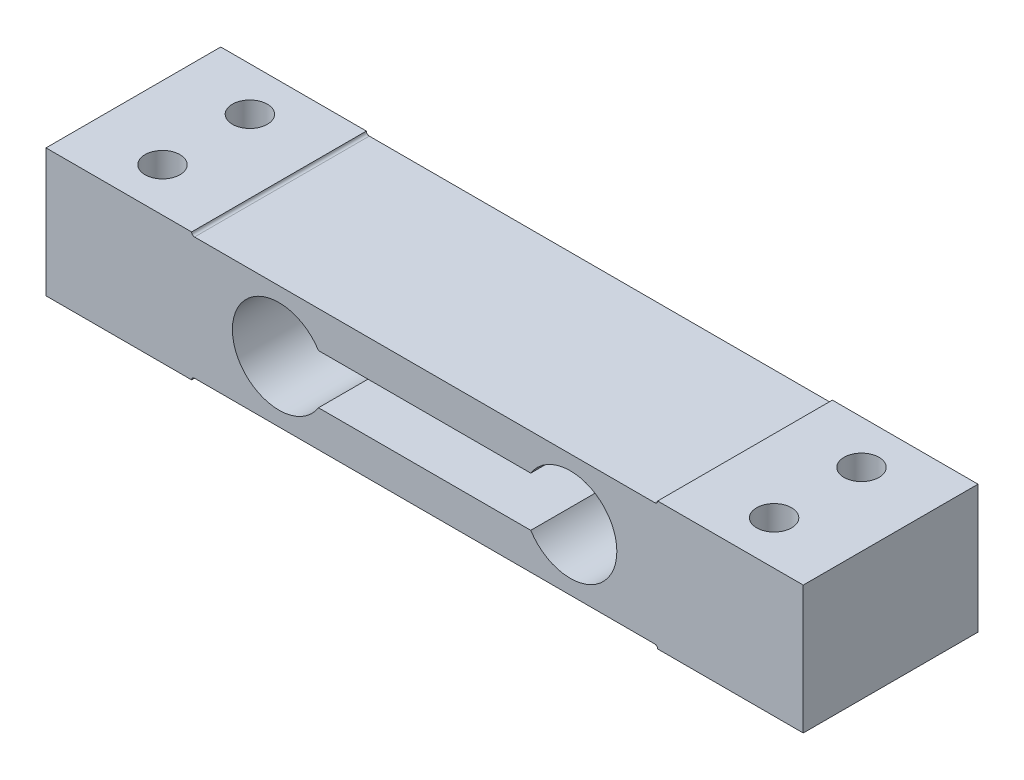
from build123d import *

# Parameters (mm, degrees)
EXTRUDE_1_DEPTH     = 30
SKETCH_2_R          = 3
CUT_EXTRUDE_1_DEPTH = 22
CUT_EXTRUDE_2_DEPTH = 30


with BuildPart() as part:
    # 스케치1 → 보스-돌출1 (new body)
    with BuildSketch(Plane.XY):
        with BuildLine():
            Line((40, 11), (65, 11))
            Line((65, 11), (65, -11))
            Line((65, -11), (40, -11))
            ThreePointArc((40, -11), (39.853553391, -10.646446609), (39.5, -10.5))
            Line((39.5, -10.5), (-39.5, -10.5))
            ThreePointArc((-39.5, -10.5), (-39.853553391, -10.646446609), (-40, -11))
            Line((-40, -11), (-65, -11))
            Line((-65, -11), (-65, 11))
            Line((-65, 11), (-40, 11))
            ThreePointArc((-40, 11), (-39.853553391, 10.646446609), (-39.5, 10.5))
            Line((-39.5, 10.5), (39.5, 10.5))
            ThreePointArc((39.5, 10.5), (39.853553391, 10.646446609), (40, 11))
        make_face()
    extrude(amount=EXTRUDE_1_DEPTH)

    # 스케치2 → 컷-돌출1 (cut)
    with BuildSketch(Plane(origin=(0, 11, 0), x_dir=(1, 0, 0), z_dir=(0, 1, 0))):
        with Locations((52.5, -7.5)):
            Circle(SKETCH_2_R)
        with Locations((52.5, -22.5)):
            Circle(SKETCH_2_R)
        with Locations((-52.5, -7.5)):
            Circle(SKETCH_2_R)
        with Locations((-52.5, -22.5)):
            Circle(SKETCH_2_R)
    extrude(amount=-CUT_EXTRUDE_1_DEPTH, mode=Mode.SUBTRACT)

    # 스케치4 → 컷-돌출2 (cut)
    with BuildSketch(Plane(origin=(0, 0, 0), x_dir=(-1, 0, 0), z_dir=(0, 0, -1))):
        with BuildLine():
            Line((-18.222279144, 4.25), (18.222279144, 4.25))
            ThreePointArc((18.222279144, 4.25), (33, 0), (18.222279144, -4.25))
            Line((18.222279144, -4.25), (-18.222279144, -4.25))
            ThreePointArc((-18.222279144, -4.25), (-33, 0), (-18.222279144, 4.25))
        make_face()
    extrude(amount=-CUT_EXTRUDE_2_DEPTH, mode=Mode.SUBTRACT)


solid = part.part
